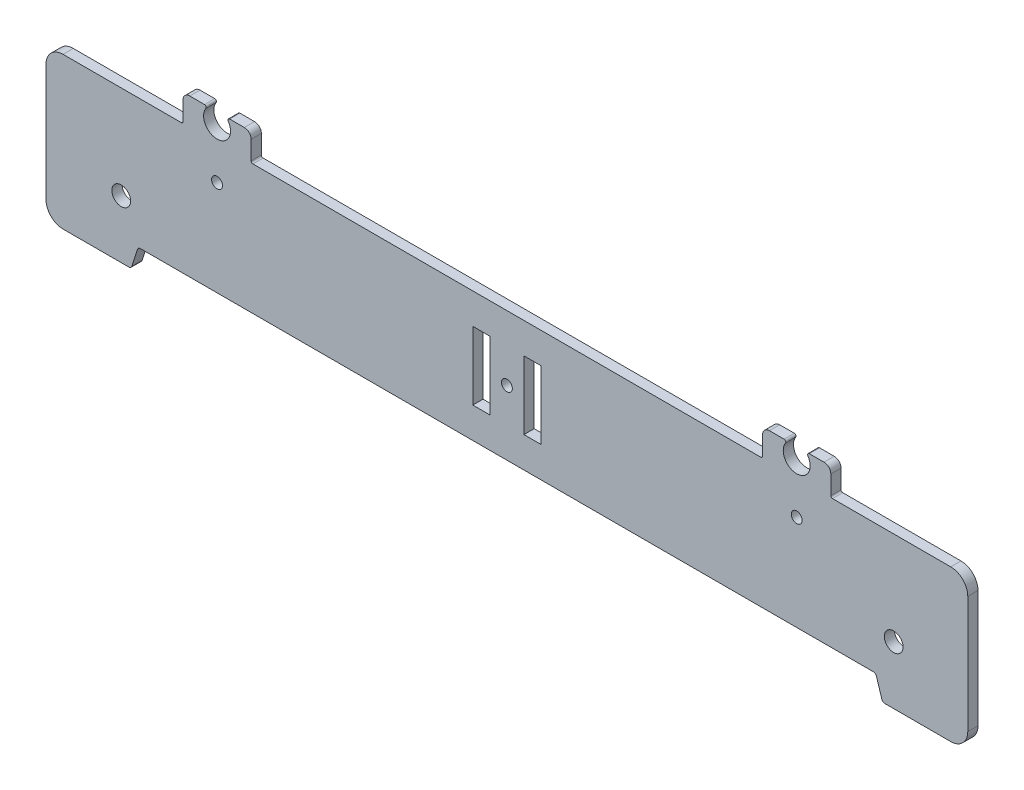
from build123d import *

# Parameters (mm, degrees)
MODEL_R                 = 1.6
MODEL_R_2               = 2.75
SALIENTE_EXTRUIR1_DEPTH = 3


with BuildPart() as part:
    # Model → Saliente-Extruir1 (new body)
    with BuildSketch(Plane.XY):
        with BuildLine():
            Line((144.039845711, 7.686598643), (36.599610491, 7.689028995))
            ThreePointArc((36.599610491, 7.689028995), (36.007496688, 7.494883352), (35.645295516, 6.987831485))
            Line((35.645295516, 6.987831485), (34.084390906, 2.002616506))
            ThreePointArc((34.084390906, 2.002616506), (33.722189733, 1.495564638), (33.13007593, 1.301418995))
            Line((33.13007593, 1.301418995), (13.864845567, 1.301418995))
            ThreePointArc((13.864845567, 1.301418995), (10.329310138, 2.765884256), (8.864843211, 6.301418995))
            Line((8.864843211, 6.301418995), (8.864843211, 40.689013995))
            ThreePointArc((8.864843211, 40.689013995), (10.329309305, 44.224547901), (13.864843211, 45.689013995))
            Line((13.864843211, 45.689013995), (18.864843211, 45.689013995))
            Line((18.864843211, 45.689013995), (48.537347211, 45.689013995))
            ThreePointArc((48.537347211, 45.689013995), (48.890900602, 45.835460605), (49.037347211, 46.189013995))
            Line((49.037347211, 46.189013995), (49.037347211, 51.687033995))
            ThreePointArc((49.037347211, 51.687033995), (49.623133649, 53.101247558), (51.037347211, 53.687033995))
            Line((51.037347211, 53.687033995), (55.353499808, 53.687033995))
            ThreePointArc((55.353499808, 53.687033995), (55.795226216, 53.421294067), (55.767415247, 52.906545119))
            ThreePointArc((55.767415247, 52.906545119), (59.037347211, 46.740682995), (62.307279175, 52.906545119))
            ThreePointArc((62.307279175, 52.906545119), (62.279468206, 53.421294067), (62.721194613, 53.687033995))
            Line((62.721194613, 53.687033995), (67.037347211, 53.687033995))
            ThreePointArc((67.037347211, 53.687033995), (68.451560774, 53.101247558), (69.037347211, 51.687033995))
            Line((69.037347211, 51.687033995), (69.037347211, 46.189010995))
            ThreePointArc((69.037347211, 46.189010995), (69.183793821, 45.835457605), (69.537347211, 45.689010995))
            Line((69.537347211, 45.689010995), (144.039845711, 45.689012495))
            Line((144.039845711, 45.689012495), (218.542344211, 45.689010995))
            ThreePointArc((218.542344211, 45.689010995), (218.895897602, 45.835457605), (219.042344211, 46.189010995))
            Line((219.042344211, 46.189010995), (219.042344211, 51.687033995))
            ThreePointArc((219.042344211, 51.687033995), (219.628130649, 53.101247558), (221.042344211, 53.687033995))
            Line((221.042344211, 53.687033995), (225.358496809, 53.687033995))
            ThreePointArc((225.358496809, 53.687033995), (225.800223216, 53.421294066), (225.772412247, 52.906545119))
            ThreePointArc((225.772412247, 52.906545119), (229.042344211, 46.740682996), (232.312276176, 52.906545119))
            ThreePointArc((232.312276176, 52.906545119), (232.284465207, 53.421294067), (232.726191614, 53.687033995))
            Line((232.726191614, 53.687033995), (237.042344211, 53.687033995))
            ThreePointArc((237.042344211, 53.687033995), (238.456557774, 53.101247558), (239.042344211, 51.687033995))
            Line((239.042344211, 51.687033995), (239.042344211, 46.189013995))
            ThreePointArc((239.042344211, 46.189013995), (239.188790821, 45.835460605), (239.542344211, 45.689013995))
            Line((239.542344211, 45.689013995), (269.214848211, 45.689013995))
            Line((269.214848211, 45.689013995), (274.214848211, 45.689013995))
            ThreePointArc((274.214848211, 45.689013995), (277.750382117, 44.224547901), (279.214848211, 40.689013995))
            Line((279.214848211, 40.689013995), (279.214848211, 6.301418995))
            ThreePointArc((279.214848211, 6.301418995), (277.750381284, 2.765884256), (274.214845855, 1.301418995))
            Line((274.214845855, 1.301418995), (254.949615492, 1.301418995))
            ThreePointArc((254.949615492, 1.301418995), (254.357501689, 1.495564638), (253.995300517, 2.002616506))
            Line((253.995300517, 2.002616506), (252.434395907, 6.987831485))
            ThreePointArc((252.434395907, 6.987831485), (252.072194734, 7.494883352), (251.480080931, 7.689028995))
            Line((251.480080931, 7.689028995), (144.039845711, 7.686598643))
        make_face()
        with Locations((59.037347211, 35.690682995)):
            Circle(MODEL_R, mode=Mode.SUBTRACT)
        with Locations((144.039845711, 26.687805569)):
            Circle(MODEL_R, mode=Mode.SUBTRACT)
        with Locations((229.042344211, 35.690682995)):
            Circle(MODEL_R, mode=Mode.SUBTRACT)
        with Locations((30.925745711, 18.301418995)):
            Circle(MODEL_R_2, mode=Mode.SUBTRACT)
        with Locations((257.483911711, 18.301418995)):
            Circle(MODEL_R_2, mode=Mode.SUBTRACT)
        Polygon((154.039845711, 36.687805569), (149.039845711, 36.687805569), (149.039845711, 16.687805569), (154.039845711, 16.687805569), (154.039845711, 26.687805569), align=None, mode=Mode.SUBTRACT)
        Polygon((134.039845711, 36.687805569), (139.039845711, 36.687805569), (139.039845711, 16.687805569), (134.039845711, 16.687805569), (134.039845711, 26.687805569), align=None, mode=Mode.SUBTRACT)
    extrude(amount=SALIENTE_EXTRUIR1_DEPTH)


solid = part.part
